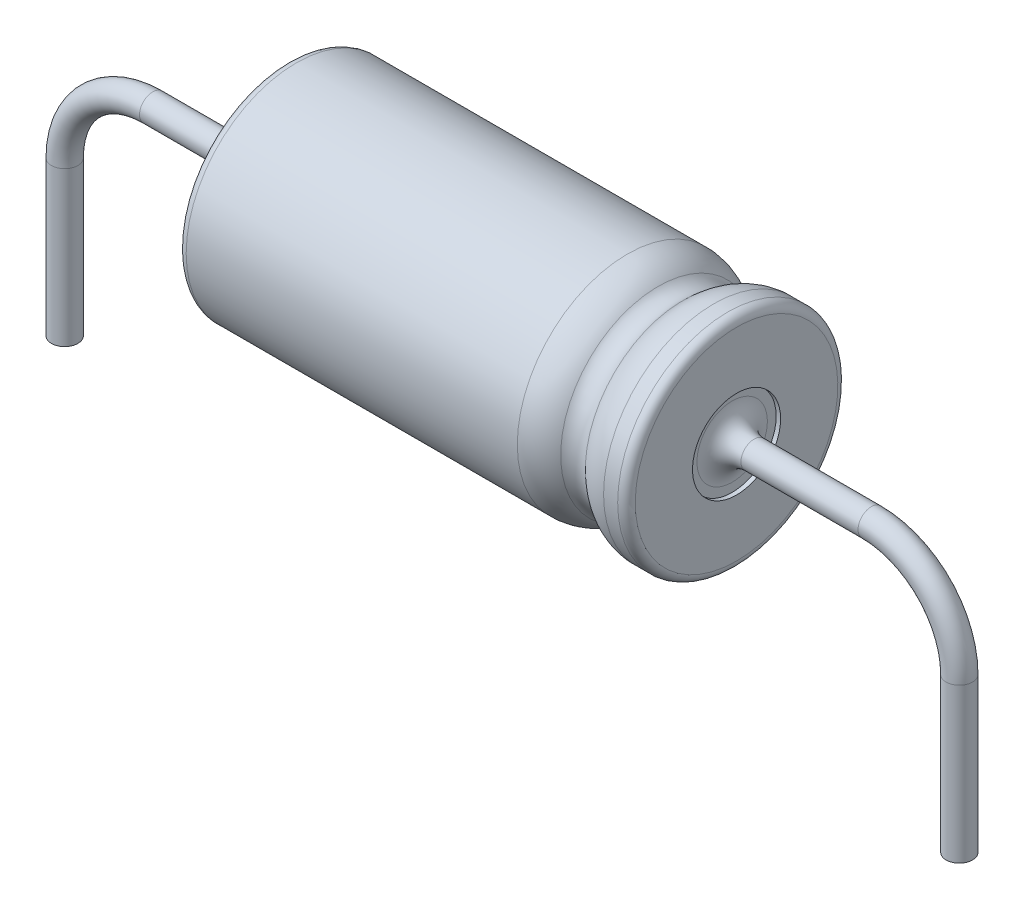
from build123d import *

# Parameters (mm, degrees)
SKETCH2_R                = 1
CUT_EXTRUDE1_DEPTH       = 0.1
SKETCH3_R                = 1
CUT_EXTRUDE2_DEPTH       = 0.1
FILLET1_R                = 0.2
SKETCH4_R                = 0.3
BOSS_EXTRUDE1_DEPTH      = 0.62
BOSS_EXTRUDE1_DEPTH_BACK = 10.62
FILLET2_R                = 0.5
SKETCH7_R                = 0.3


with BuildPart() as part:
    # Sketch1 → Base-Revolve-Thin (revolve)
    with BuildSketch(Plane.XY):
        Polygon((-15.26000004, 2.5), (-15.26000004, 5), (-5.06000004, 5), (-5.06000004, 2.5), (-6.06000004, 2.5), (-6.06000004, 4), (-14.26000004, 4), (-14.26000004, 2.5), align=None)
    revolve(axis=Axis((-5.06000004, 2.5, 0), (-1, 0, 0)))

    # Sketch2 → Cut-Extrude1 (cut)
    with BuildSketch(Plane(origin=(-5.06000004, 0, 0), x_dir=(0, 0, -1), z_dir=(1, 0, 0))):
        with Locations((0, 2.5)):
            Circle(SKETCH2_R)
    extrude(amount=-CUT_EXTRUDE1_DEPTH, mode=Mode.SUBTRACT)

    # Sketch3 → Cut-Extrude2 (cut)
    with BuildSketch(Plane.ZY.offset(15.26000004)):
        with Locations((0, 2.5)):
            Circle(SKETCH3_R)
    extrude(amount=-CUT_EXTRUDE2_DEPTH, mode=Mode.SUBTRACT)

    # Fillet1
    fillet1_edges = [part.edges().sort_by_distance(p)[0] for p in [
        (-15.26000004, 0, 0),
        (-5.06000004, 0, 0),
    ]]
    fillet(fillet1_edges, radius=FILLET1_R)

    # Sketch4 → Boss-Extrude1 (add, two sides)
    with BuildSketch(Plane(origin=(-5.16000004, 0, 0), x_dir=(0, 0, -1), z_dir=(1, 0, 0))) as boss_extrude1_sk:
        with Locations((0, 2.5)):
            Circle(SKETCH4_R)
    extrude(amount=BOSS_EXTRUDE1_DEPTH)
    extrude(boss_extrude1_sk.sketch, amount=-BOSS_EXTRUDE1_DEPTH_BACK)

    # Fillet2
    fillet2_edges = [part.edges().sort_by_distance(p)[0] for p in [
        (-5.16000004, 2.5, 0.3),
        (-15.16000004, 2.5, 0.3),
    ]]
    fillet(fillet2_edges, radius=FILLET2_R)

    # Boss-Sweep2: sweep along a path in Sketch5
    with BuildLine(Plane.XY) as boss_sweep2_path:
        Line((0, -3), (0, 0.5))
        ThreePointArc((0, 0.5), (-0.585786438, 1.914213562), (-2, 2.5))
        Line((-2, 2.5), (-4.54000004, 2.5))
    # Sketch7 → Boss-Sweep2 (sweep)
    with BuildSketch(Plane(origin=(-4.54000004, 0, 0), x_dir=(0, 0, -1), z_dir=(1, 0, 0))):
        with Locations((0, 2.5)):
            Circle(SKETCH7_R)
    boss_sweep2 = sweep(path=boss_sweep2_path.line)

    # Mirror1: Boss-Sweep2 across plane
    add(boss_sweep2.mirror(Plane(origin=(-10.16000004, 0, 0), x_dir=(0, 0, 1), z_dir=(1, 0, 0))))

    # Sketch8 → Cut-Revolve1 (revolve, cut)
    with BuildSketch(Plane.XY):
        with BuildLine():
            Line((-5.580246119, 5), (-7.539837097, 5))
            ThreePointArc((-7.539837097, 5), (-7.161872813, 4.925820177), (-6.839983176, 4.714286))
            ThreePointArc((-6.839983176, 4.714286), (-6.560041608, 4.6000004), (-6.28010004, 4.714286))
            ThreePointArc((-6.28010004, 4.714286), (-5.958210403, 4.925820177), (-5.580246119, 5))
        make_face()
    revolve(axis=Axis((-2.979129248, 2.5, 0), (-1, 0, 0)), mode=Mode.SUBTRACT)


solid = part.part
